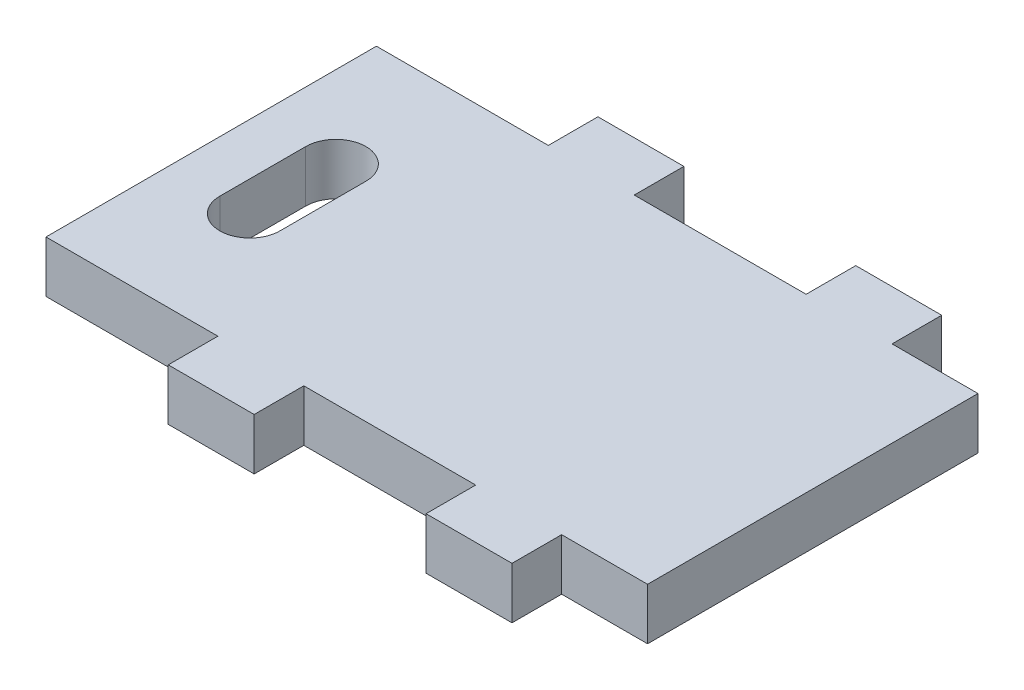
from build123d import *

# Parameters (mm, degrees)
SKETCH1_W           = 60
SKETCH1_H           = 50
BOSS_EXTRUDE1_DEPTH = 6
SKETCH3_W           = 10
SKETCH3_H           = 5.775633532
SKETCH3_W_2         = 20
CUT_EXTRUDE2_DEPTH  = 7
SKETCH4_W           = 10
SKETCH4_H           = 38.448732936
BOSS_EXTRUDE2_DEPTH = 6
CUT_EXTRUDE3_DEPTH  = 7


with BuildPart() as part:
    # Sketch1 → Boss-Extrude1 (new body)
    with BuildSketch(Plane(origin=(0, 0, 0), x_dir=(1, 0, 0), z_dir=(0, 1, 0))):
        with Locations((5, 0)):
            Rectangle(SKETCH1_W, SKETCH1_H)
    extrude(amount=BOSS_EXTRUDE1_DEPTH)

    # Sketch3 → Cut-Extrude2 (cut, through all)
    with BuildSketch(Plane(origin=(0, 6, 0), x_dir=(1, 0, 0), z_dir=(0, 1, 0))):
        with Locations((30, 22.112183234)):
            Rectangle(SKETCH3_W, SKETCH3_H)
        with Locations((5, 22.112183234)):
            Rectangle(SKETCH3_W_2, SKETCH3_H)
        with Locations((-20, 22.112183234)):
            Rectangle(SKETCH3_W, SKETCH3_H)
    cut_extrude2 = extrude(amount=-CUT_EXTRUDE2_DEPTH, mode=Mode.SUBTRACT)

    # Mirror2: Cut-Extrude2 across plane
    add(cut_extrude2.mirror(Plane.XY), mode=Mode.SUBTRACT)

    # Sketch4 → Boss-Extrude2 (add)
    with BuildSketch(Plane(origin=(0, 6, 0), x_dir=(1, 0, 0), z_dir=(0, 1, 0))):
        with Locations((-30, 0)):
            Rectangle(SKETCH4_W, SKETCH4_H)
    extrude(amount=-BOSS_EXTRUDE2_DEPTH)

    # Sketch5 → Cut-Extrude3 (cut, through all)
    with BuildSketch(Plane(origin=(0, 6, 0), x_dir=(1, 0, 0), z_dir=(0, 1, 0))):
        with BuildLine():
            Line((-22, -5), (-22, 5))
            ThreePointArc((-22, 5), (-25.5, 8.5), (-29, 5))
            Line((-29, 5), (-29, -5))
            ThreePointArc((-29, -5), (-25.5, -8.5), (-22, -5))
        make_face()
    extrude(amount=-CUT_EXTRUDE3_DEPTH, mode=Mode.SUBTRACT)


solid = part.part
